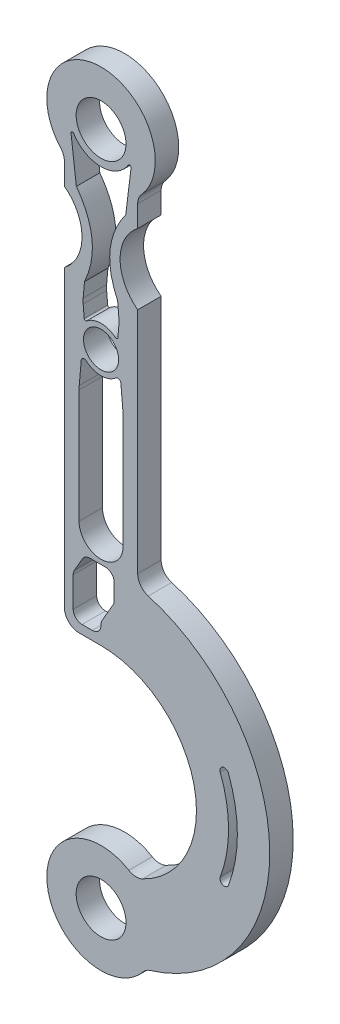
from build123d import *

# Parameters (mm, degrees)
SKETCH1_R           = 6
SKETCH1_R_2         = 8.5
BOSS_EXTRUDE1_DEPTH = 8
FILLET1_R           = 5


with BuildPart() as part:
    # Sketch1 → Boss-Extrude1 (new body)
    with BuildSketch(Plane.XY):
        with BuildLine():
            ThreePointArc((12.5, -13.638181697), (0, 18.5), (-12.5, -13.638181697))
            Line((-12.5, -13.638181697), (-12.5, -23))
            ThreePointArc((-12.5, -23), (-6.5, -35), (-12.5, -47))
            Line((-12.5, -47), (-12.5, -152.456671403))
            Line((-12.5, -152.456671403), (0, -152.456671403))
            ThreePointArc((0, -152.456671403), (32.019441409, -179.184193262), (11.444366088, -215.464647068))
            ThreePointArc((11.444366088, -215.464647068), (-18.29086587, -232.773846738), (15.239317045, -240.488718511))
            ThreePointArc((15.239317045, -240.488718511), (57.52601951, -183.58870793), (12.5, -128.830749818))
            Line((12.5, -128.830749818), (12.5, -47))
            ThreePointArc((12.5, -47), (6.5, -35), (12.5, -23))
            Line((12.5, -23), (12.5, -13.638181697))
        make_face()
        with BuildLine():
            ThreePointArc((8.333859781, -228.327642037), (8.458362966, -229.159704854), (8.5, -230))
            ThreePointArc((8.5, -230), (-8.458362966, -230.840295146), (8.333859781, -228.327642037))
        make_face(mode=Mode.SUBTRACT)
        with BuildLine():
            ThreePointArc((0, -146.456671403), (-0.878679656, -148.577991747), (-3, -149.456671403))
            Line((-3, -149.456671403), (-6.5, -149.456671403))
            ThreePointArc((-6.5, -149.456671403), (-8.621320344, -148.577991747), (-9.5, -146.456671403))
            Line((-9.5, -146.456671403), (-9.5, -136.26051898))
            ThreePointArc((-9.5, -136.26051898), (-9.397777479, -135.484061845), (-9.098076211, -134.76051898))
            Line((-9.098076211, -134.76051898), (-6.366025404, -130.028468173))
            ThreePointArc((-6.366025404, -130.028468173), (-5.267949192, -128.930391962), (-3.767949192, -128.528468173))
            Line((-3.767949192, -128.528468173), (1.5, -128.528468173))
            ThreePointArc((1.5, -128.528468173), (3.621320344, -129.407147829), (4.5, -131.528468173))
            Line((4.5, -131.528468173), (4.5, -136.858595192))
            ThreePointArc((4.5, -136.858595192), (4.397777479, -137.635052327), (4.098076211, -138.358595192))
            Line((4.098076211, -138.358595192), (0.401923789, -144.76051898))
            ThreePointArc((0.401923789, -144.76051898), (0.102222521, -145.484061845), (0, -146.26051898))
            Line((0, -146.26051898), (0, -146.456671403))
        make_face(mode=Mode.SUBTRACT)
        with BuildLine():
            ThreePointArc((43.461464413, -168.466666667), (46.5, -185), (43.461464413, -201.533333333))
            ThreePointArc((43.461464413, -201.533333333), (41.526148356, -202.401982723), (40.657498967, -200.466666667))
            ThreePointArc((40.657498967, -200.466666667), (43.5, -185), (40.657498967, -169.533333333))
            ThreePointArc((40.657498967, -169.533333333), (41.526148356, -167.598017277), (43.461464413, -168.466666667))
        make_face(mode=Mode.SUBTRACT)
        with BuildLine():
            ThreePointArc((7.5, -119.456671403), (0, -126.956671403), (-7.5, -119.456671403))
            Line((-7.5, -119.456671403), (-7.5, -80.654914144))
            ThreePointArc((-7.5, -80.654914144), (-7.485723324, -80.000623333), (-7.442920471, -79.347578002))
            Line((-7.442920471, -79.347578002), (-6.756300289, -71.499473409))
            ThreePointArc((-6.756300289, -71.499473409), (-6.133334804, -70.658889988), (-5.101807809, -70.833871534))
            ThreePointArc((-5.101807809, -70.833871534), (0, -72.75), (5.101807809, -70.833871534))
            ThreePointArc((5.101807809, -70.833871534), (6.133334804, -70.658889988), (6.756300289, -71.499473409))
            Line((6.756300289, -71.499473409), (7.442920471, -79.347578002))
            ThreePointArc((7.442920471, -79.347578002), (7.485723324, -80.000623333), (7.5, -80.654914144))
            Line((7.5, -80.654914144), (7.5, -119.456671403))
        make_face(mode=Mode.SUBTRACT)
        with Locations((0, -65)):
            Circle(SKETCH1_R, mode=Mode.SUBTRACT)
        with BuildLine():
            Line((-8.421524221, -21), (-10.243145112, -6.164088407))
            ThreePointArc((-10.243145112, -6.164088407), (-9.913994973, -5.631910779), (-9.323094991, -5.837799225))
            ThreePointArc((-9.323094991, -5.837799225), (0, -11), (9.323094991, -5.837799225))
            ThreePointArc((9.323094991, -5.837799225), (9.913994973, -5.631910779), (10.243145112, -6.164088407))
            Line((10.243145112, -6.164088407), (8.421524221, -21))
            add(Edge.make_bspline(
                [(5.648127088, -47.738954624), (-0.877088936, -33.717206836), (8.421524221, -21)],
                knots=[0, 0, 0, 1, 1, 1], degree=2))
            Line((5.648127088, -47.738954624), (6.09481015, -52.844565385))
            ThreePointArc((6.09481015, -52.844565385), (6.132863169, -53.716122812), (6.09481015, -54.58768024))
            Line((6.09481015, -54.58768024), (5.737570571, -58.670947304))
            ThreePointArc((5.737570571, -58.670947304), (5.433124471, -59.088345781), (4.921929391, -59.013589467))
            ThreePointArc((4.921929391, -59.013589467), (0, -57.25), (-4.921929391, -59.013589467))
            ThreePointArc((-4.921929391, -59.013589467), (-5.433124471, -59.088345781), (-5.737570571, -58.670947304))
            Line((-5.737570571, -58.670947304), (-6.09481015, -54.58768024))
            ThreePointArc((-6.09481015, -54.58768024), (-6.132863169, -53.716122812), (-6.09481015, -52.844565385))
            Line((-6.09481015, -52.844565385), (-5.648127088, -47.738954624))
            add(Edge.make_bspline(
                [(-5.648127088, -47.738954624), (0.877088936, -33.717206836), (-8.421524221, -21)],
                knots=[0, 0, 0, 1, 1, 1], degree=2))
        make_face(mode=Mode.SUBTRACT)
        Circle(SKETCH1_R_2, mode=Mode.SUBTRACT)
    extrude(amount=BOSS_EXTRUDE1_DEPTH)

    # Fillet1
    fillet1_edges = [part.edges().sort_by_distance(p)[0] for p in [
        (11.444366088, -215.464647068, 4),
        (-12.5, -152.456671403, 4),
        (-12.5, -13.638181697, 4),
        (12.5, -13.638181697, 4),
        (12.5, -128.830749818, 4),
        (15.239317045, -240.488718511, 4),
    ]]
    fillet(fillet1_edges, radius=FILLET1_R)


solid = part.part
